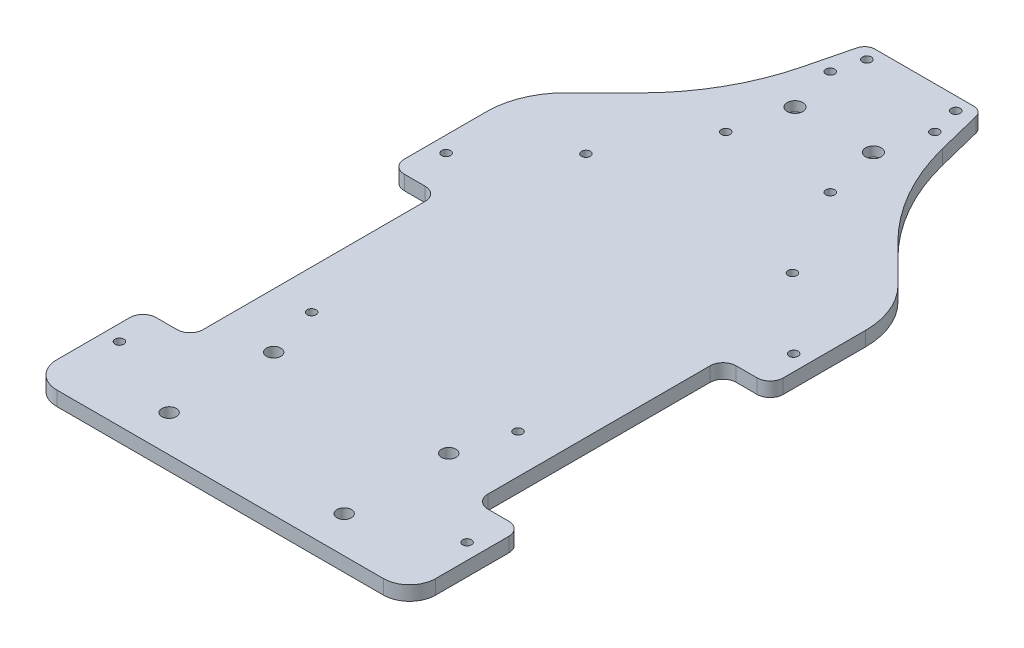
from build123d import *

# Parameters (mm, degrees)
DECK_BASE_DEPTH     = 5.5
BOLT_SLOT_REACH     = 7.5
SKETCH_3_R          = 1.7
FILLET_1_R          = 4
CUT_SIDE_REACH      = 7.5
SKETCH_11_W         = 18
SKETCH_11_H         = 95
CUT_TAIL_REACH      = 7.5
SKETCH_10_W         = 145
SKETCH_10_H         = 38.5
FILLET_2_R          = 10
FILLET_3_R          = 5
LIDAR_SLOT_REACH    = 7.5
SKETCH_4_R          = 1.7
VESC_SLOT_REACH     = 7.5
SKETCH_6_R          = 2.75
NANO_SLOT_REACH     = 7.5
SKETCH_7_R          = 1.7
CUT_EXTRUDE_3_REACH = 7.5
SKETCH_12_R         = 1.75
SKETCH_13_R         = 3
CUT_EXTRUDE_4_DEPTH = 3.7


with BuildPart() as part:
    # 스케치1 → Deck base (new body)
    with BuildSketch(Plane(origin=(0, 0, 0), x_dir=(1, 0, 0), z_dir=(0, 1, 0))):
        with BuildLine():
            Line((-72.5, 0), (-72.5, -180))
            ThreePointArc((-72.5, -180), (-69.571067812, -187.071067812), (-62.5, -190))
            Line((-62.5, -190), (-49.196112248, -190))
            ThreePointArc((-49.196112248, -190), (-47.589899161, -190.265015363), (-46.15395453, -191.031968194))
            Line((-46.15395453, -191.031968194), (-18.84604547, -211.968031806))
            ThreePointArc((-18.84604547, -211.968031806), (-17.410100839, -212.734984637), (-15.803887752, -213))
            Line((-15.803887752, -213), (15.803887752, -213))
            ThreePointArc((15.803887752, -213), (17.410100839, -212.734984637), (18.84604547, -211.968031806))
            Line((18.84604547, -211.968031806), (46.15395453, -191.031968194))
            ThreePointArc((46.15395453, -191.031968194), (47.589899161, -190.265015363), (49.196112248, -190))
            Line((49.196112248, -190), (62.5, -190))
            ThreePointArc((62.5, -190), (69.571067812, -187.071067812), (72.5, -180))
            Line((72.5, -180), (72.5, 0))
            ThreePointArc((72.5, 0), (70.204904333, 11.508182998), (63.670781605, 21.255540601))
            Line((63.670781605, 21.255540601), (49.478231298, 35.391496426))
            ThreePointArc((49.478231298, 35.391496426), (35.536990456, 53.662264501), (27, 75))
            Line((27, 75), (22, 95))
            Line((22, 95), (-22, 95))
            Line((-22, 95), (-27, 75))
            ThreePointArc((-27, 75), (-35.536990456, 53.662264501), (-49.478231298, 35.391496426))
            Line((-49.478231298, 35.391496426), (-63.670781605, 21.255540601))
            ThreePointArc((-63.670781605, 21.255540601), (-70.204904333, 11.508182998), (-72.5, 0))
        make_face()
    extrude(amount=DECK_BASE_DEPTH)

    # 스케치3 → Bolt slot (cut, up to next)
    with BuildSketch(Plane(origin=(0, 5.5, 0), x_dir=(1, 0, 0), z_dir=(0, 1, 0)), mode=Mode.PRIVATE) as bolt_slot_sk1:
        with Locations((17, 90)):
            Circle(SKETCH_3_R)
    bolt_slot_tool1 = extrude(bolt_slot_sk1.sketch, amount=-BOLT_SLOT_REACH, mode=Mode.PRIVATE) & part.part
    add(bolt_slot_tool1.solids().sort_by_distance((17, 5.5, -90))[0], mode=Mode.SUBTRACT)
    # 스케치3 → Bolt slot (cut, up to next)
    with BuildSketch(Plane(origin=(0, 5.5, 0), x_dir=(1, 0, 0), z_dir=(0, 1, 0)), mode=Mode.PRIVATE) as bolt_slot_sk2:
        with Locations((66.5, -146.5)):
            Circle(SKETCH_3_R)
    bolt_slot_tool2 = extrude(bolt_slot_sk2.sketch, amount=-BOLT_SLOT_REACH, mode=Mode.PRIVATE) & part.part
    add(bolt_slot_tool2.solids().sort_by_distance((66.5, 5.5, 146.5))[0], mode=Mode.SUBTRACT)
    # 스케치3 → Bolt slot (cut, up to next)
    with BuildSketch(Plane(origin=(0, 5.5, 0), x_dir=(1, 0, 0), z_dir=(0, 1, 0)), mode=Mode.PRIVATE) as bolt_slot_sk3:
        with Locations((66.5, -116.5)):
            Circle(SKETCH_3_R)
    bolt_slot_tool3 = extrude(bolt_slot_sk3.sketch, amount=-BOLT_SLOT_REACH, mode=Mode.PRIVATE) & part.part
    add(bolt_slot_tool3.solids().sort_by_distance((66.5, 5.5, 116.5))[0], mode=Mode.SUBTRACT)
    # 스케치3 → Bolt slot (cut, up to next)
    with BuildSketch(Plane(origin=(0, 5.5, 0), x_dir=(1, 0, 0), z_dir=(0, 1, 0)), mode=Mode.PRIVATE) as bolt_slot_sk4:
        with Locations((66.5, -51.5)):
            Circle(SKETCH_3_R)
    bolt_slot_tool4 = extrude(bolt_slot_sk4.sketch, amount=-BOLT_SLOT_REACH, mode=Mode.PRIVATE) & part.part
    add(bolt_slot_tool4.solids().sort_by_distance((66.5, 5.5, 51.5))[0], mode=Mode.SUBTRACT)
    # 스케치3 → Bolt slot (cut, up to next)
    with BuildSketch(Plane(origin=(0, 5.5, 0), x_dir=(1, 0, 0), z_dir=(0, 1, 0)), mode=Mode.PRIVATE) as bolt_slot_sk5:
        with Locations((66.5, -21.5)):
            Circle(SKETCH_3_R)
    bolt_slot_tool5 = extrude(bolt_slot_sk5.sketch, amount=-BOLT_SLOT_REACH, mode=Mode.PRIVATE) & part.part
    add(bolt_slot_tool5.solids().sort_by_distance((66.5, 5.5, 21.5))[0], mode=Mode.SUBTRACT)
    # 스케치3 → Bolt slot (cut, up to next)
    with BuildSketch(Plane(origin=(0, 5.5, 0), x_dir=(1, 0, 0), z_dir=(0, 1, 0)), mode=Mode.PRIVATE) as bolt_slot_sk6:
        with Locations((-66.5, -21.5)):
            Circle(SKETCH_3_R)
    bolt_slot_tool6 = extrude(bolt_slot_sk6.sketch, amount=-BOLT_SLOT_REACH, mode=Mode.PRIVATE) & part.part
    add(bolt_slot_tool6.solids().sort_by_distance((-66.5, 5.5, 21.5))[0], mode=Mode.SUBTRACT)
    # 스케치3 → Bolt slot (cut, up to next)
    with BuildSketch(Plane(origin=(0, 5.5, 0), x_dir=(1, 0, 0), z_dir=(0, 1, 0)), mode=Mode.PRIVATE) as bolt_slot_sk7:
        with Locations((-66.5, -51.5)):
            Circle(SKETCH_3_R)
    bolt_slot_tool7 = extrude(bolt_slot_sk7.sketch, amount=-BOLT_SLOT_REACH, mode=Mode.PRIVATE) & part.part
    add(bolt_slot_tool7.solids().sort_by_distance((-66.5, 5.5, 51.5))[0], mode=Mode.SUBTRACT)
    # 스케치3 → Bolt slot (cut, up to next)
    with BuildSketch(Plane(origin=(0, 5.5, 0), x_dir=(1, 0, 0), z_dir=(0, 1, 0)), mode=Mode.PRIVATE) as bolt_slot_sk8:
        with Locations((-66.5, -116.5)):
            Circle(SKETCH_3_R)
    bolt_slot_tool8 = extrude(bolt_slot_sk8.sketch, amount=-BOLT_SLOT_REACH, mode=Mode.PRIVATE) & part.part
    add(bolt_slot_tool8.solids().sort_by_distance((-66.5, 5.5, 116.5))[0], mode=Mode.SUBTRACT)
    # 스케치3 → Bolt slot (cut, up to next)
    with BuildSketch(Plane(origin=(0, 5.5, 0), x_dir=(1, 0, 0), z_dir=(0, 1, 0)), mode=Mode.PRIVATE) as bolt_slot_sk9:
        with Locations((-66.5, -146.5)):
            Circle(SKETCH_3_R)
    bolt_slot_tool9 = extrude(bolt_slot_sk9.sketch, amount=-BOLT_SLOT_REACH, mode=Mode.PRIVATE) & part.part
    add(bolt_slot_tool9.solids().sort_by_distance((-66.5, 5.5, 146.5))[0], mode=Mode.SUBTRACT)
    # 스케치3 → Bolt slot (cut, up to next)
    with BuildSketch(Plane(origin=(0, 5.5, 0), x_dir=(1, 0, 0), z_dir=(0, 1, 0)), mode=Mode.PRIVATE) as bolt_slot_sk10:
        with Locations((-17, 90)):
            Circle(SKETCH_3_R)
    bolt_slot_tool10 = extrude(bolt_slot_sk10.sketch, amount=-BOLT_SLOT_REACH, mode=Mode.PRIVATE) & part.part
    add(bolt_slot_tool10.solids().sort_by_distance((-17, 5.5, -90))[0], mode=Mode.SUBTRACT)

    # 필렛1
    fillet_1_edges = [part.edges().sort_by_distance(p)[0] for p in [
        (22, 2.75, -95),
        (-22, 2.75, -95),
    ]]
    fillet(fillet_1_edges, radius=FILLET_1_R)

    # 스케치11 → Cut side (cut, up to next)
    with BuildSketch(Plane(origin=(0, 5.5, 0), x_dir=(1, 0, 0), z_dir=(0, 1, 0)), mode=Mode.PRIVATE) as cut_side_sk1:
        with Locations((-63.5, -84)):
            Rectangle(SKETCH_11_W, SKETCH_11_H)
    cut_side_tool1 = extrude(cut_side_sk1.sketch, amount=-CUT_SIDE_REACH, mode=Mode.PRIVATE) & part.part
    add(cut_side_tool1.solids().sort_by_distance((-63.5, 5.5, 84))[0], mode=Mode.SUBTRACT)
    # 스케치11 → Cut side (cut, up to next)
    with BuildSketch(Plane(origin=(0, 5.5, 0), x_dir=(1, 0, 0), z_dir=(0, 1, 0)), mode=Mode.PRIVATE) as cut_side_sk2:
        with Locations((63.5, -84)):
            Rectangle(SKETCH_11_W, SKETCH_11_H)
    cut_side_tool2 = extrude(cut_side_sk2.sketch, amount=-CUT_SIDE_REACH, mode=Mode.PRIVATE) & part.part
    add(cut_side_tool2.solids().sort_by_distance((63.5, 5.5, 84))[0], mode=Mode.SUBTRACT)

    # 스케치10 → Cut tail (cut, up to next)
    with BuildSketch(Plane(origin=(0, 5.5, 0), x_dir=(1, 0, 0), z_dir=(0, 1, 0)), mode=Mode.PRIVATE) as cut_tail_sk1:
        with Locations((0, -193.75)):
            Rectangle(SKETCH_10_W, SKETCH_10_H)
    cut_tail_tool1 = extrude(cut_tail_sk1.sketch, amount=-CUT_TAIL_REACH, mode=Mode.PRIVATE) & part.part
    add(cut_tail_tool1.solids().sort_by_distance((0, 5.5, 193.75))[0], mode=Mode.SUBTRACT)

    # 필렛2
    fillet_2_edges = [part.edges().sort_by_distance(p)[0] for p in [
        (72.5, 2.75, 174.5),
        (-72.5, 2.75, 174.5),
    ]]
    fillet(fillet_2_edges, radius=FILLET_2_R)

    # 필렛3
    fillet_3_edges = [part.edges().sort_by_distance(p)[0] for p in [
        (-72.5, 2.75, 131.5),
        (-72.5, 2.75, 36.5),
        (-54.5, 2.75, 36.5),
        (-54.5, 2.75, 131.5),
        (72.5, 2.75, 36.5),
        (72.5, 2.75, 131.5),
        (54.5, 2.75, 131.5),
        (54.5, 2.75, 36.5),
    ]]
    fillet(fillet_3_edges, radius=FILLET_3_R)

    # 스케치4 → Lidar slot (cut, up to next)
    with BuildSketch(Plane(origin=(0, 5.5, 0), x_dir=(1, 0, 0), z_dir=(0, 1, 0)), mode=Mode.PRIVATE) as lidar_slot_sk1:
        with Locations((-20, 79)):
            Circle(SKETCH_4_R)
    lidar_slot_tool1 = extrude(lidar_slot_sk1.sketch, amount=-LIDAR_SLOT_REACH, mode=Mode.PRIVATE) & part.part
    add(lidar_slot_tool1.solids().sort_by_distance((-20, 5.5, -79))[0], mode=Mode.SUBTRACT)
    # 스케치4 → Lidar slot (cut, up to next)
    with BuildSketch(Plane(origin=(0, 5.5, 0), x_dir=(1, 0, 0), z_dir=(0, 1, 0)), mode=Mode.PRIVATE) as lidar_slot_sk2:
        with Locations((-20, 39)):
            Circle(SKETCH_4_R)
    lidar_slot_tool2 = extrude(lidar_slot_sk2.sketch, amount=-LIDAR_SLOT_REACH, mode=Mode.PRIVATE) & part.part
    add(lidar_slot_tool2.solids().sort_by_distance((-20, 5.5, -39))[0], mode=Mode.SUBTRACT)
    # 스케치4 → Lidar slot (cut, up to next)
    with BuildSketch(Plane(origin=(0, 5.5, 0), x_dir=(1, 0, 0), z_dir=(0, 1, 0)), mode=Mode.PRIVATE) as lidar_slot_sk3:
        with Locations((20, 39)):
            Circle(SKETCH_4_R)
    lidar_slot_tool3 = extrude(lidar_slot_sk3.sketch, amount=-LIDAR_SLOT_REACH, mode=Mode.PRIVATE) & part.part
    add(lidar_slot_tool3.solids().sort_by_distance((20, 5.5, -39))[0], mode=Mode.SUBTRACT)
    # 스케치4 → Lidar slot (cut, up to next)
    with BuildSketch(Plane(origin=(0, 5.5, 0), x_dir=(1, 0, 0), z_dir=(0, 1, 0)), mode=Mode.PRIVATE) as lidar_slot_sk4:
        with Locations((20, 79)):
            Circle(SKETCH_4_R)
    lidar_slot_tool4 = extrude(lidar_slot_sk4.sketch, amount=-LIDAR_SLOT_REACH, mode=Mode.PRIVATE) & part.part
    add(lidar_slot_tool4.solids().sort_by_distance((20, 5.5, -79))[0], mode=Mode.SUBTRACT)

    # 스케치6 → Vesc slot (cut, up to next)
    with BuildSketch(Plane(origin=(0, 5.5, 0), x_dir=(1, 0, 0), z_dir=(0, 1, 0)), mode=Mode.PRIVATE) as vesc_slot_sk1:
        with Locations((33.5, -120.5)):
            Circle(SKETCH_6_R)
    vesc_slot_tool1 = extrude(vesc_slot_sk1.sketch, amount=-VESC_SLOT_REACH, mode=Mode.PRIVATE) & part.part
    add(vesc_slot_tool1.solids().sort_by_distance((33.5, 5.5, 120.5))[0], mode=Mode.SUBTRACT)
    # 스케치6 → Vesc slot (cut, up to next)
    with BuildSketch(Plane(origin=(0, 5.5, 0), x_dir=(1, 0, 0), z_dir=(0, 1, 0)), mode=Mode.PRIVATE) as vesc_slot_sk2:
        with Locations((33.5, -160.5)):
            Circle(SKETCH_6_R)
    vesc_slot_tool2 = extrude(vesc_slot_sk2.sketch, amount=-VESC_SLOT_REACH, mode=Mode.PRIVATE) & part.part
    add(vesc_slot_tool2.solids().sort_by_distance((33.5, 5.5, 160.5))[0], mode=Mode.SUBTRACT)
    # 스케치6 → Vesc slot (cut, up to next)
    with BuildSketch(Plane(origin=(0, 5.5, 0), x_dir=(1, 0, 0), z_dir=(0, 1, 0)), mode=Mode.PRIVATE) as vesc_slot_sk3:
        with Locations((-33.5, -160.5)):
            Circle(SKETCH_6_R)
    vesc_slot_tool3 = extrude(vesc_slot_sk3.sketch, amount=-VESC_SLOT_REACH, mode=Mode.PRIVATE) & part.part
    add(vesc_slot_tool3.solids().sort_by_distance((-33.5, 5.5, 160.5))[0], mode=Mode.SUBTRACT)
    # 스케치6 → Vesc slot (cut, up to next)
    with BuildSketch(Plane(origin=(0, 5.5, 0), x_dir=(1, 0, 0), z_dir=(0, 1, 0)), mode=Mode.PRIVATE) as vesc_slot_sk4:
        with Locations((-33.5, -120.5)):
            Circle(SKETCH_6_R)
    vesc_slot_tool4 = extrude(vesc_slot_sk4.sketch, amount=-VESC_SLOT_REACH, mode=Mode.PRIVATE) & part.part
    add(vesc_slot_tool4.solids().sort_by_distance((-33.5, 5.5, 120.5))[0], mode=Mode.SUBTRACT)

    # 스케치7 → Nano slot (cut, up to next)
    with BuildSketch(Plane(origin=(0, 5.5, 0), x_dir=(1, 0, 0), z_dir=(0, 1, 0)), mode=Mode.PRIVATE) as nano_slot_sk1:
        with Locations((39.5, 5)):
            Circle(SKETCH_7_R)
    nano_slot_tool1 = extrude(nano_slot_sk1.sketch, amount=-NANO_SLOT_REACH, mode=Mode.PRIVATE) & part.part
    add(nano_slot_tool1.solids().sort_by_distance((39.5, 5.5, -5))[0], mode=Mode.SUBTRACT)
    # 스케치7 → Nano slot (cut, up to next)
    with BuildSketch(Plane(origin=(0, 5.5, 0), x_dir=(1, 0, 0), z_dir=(0, 1, 0)), mode=Mode.PRIVATE) as nano_slot_sk2:
        with Locations((39.5, -100)):
            Circle(SKETCH_7_R)
    nano_slot_tool2 = extrude(nano_slot_sk2.sketch, amount=-NANO_SLOT_REACH, mode=Mode.PRIVATE) & part.part
    add(nano_slot_tool2.solids().sort_by_distance((39.5, 5.5, 100))[0], mode=Mode.SUBTRACT)
    # 스케치7 → Nano slot (cut, up to next)
    with BuildSketch(Plane(origin=(0, 5.5, 0), x_dir=(1, 0, 0), z_dir=(0, 1, 0)), mode=Mode.PRIVATE) as nano_slot_sk3:
        with Locations((-39.5, -100)):
            Circle(SKETCH_7_R)
    nano_slot_tool3 = extrude(nano_slot_sk3.sketch, amount=-NANO_SLOT_REACH, mode=Mode.PRIVATE) & part.part
    add(nano_slot_tool3.solids().sort_by_distance((-39.5, 5.5, 100))[0], mode=Mode.SUBTRACT)
    # 스케치7 → Nano slot (cut, up to next)
    with BuildSketch(Plane(origin=(0, 5.5, 0), x_dir=(1, 0, 0), z_dir=(0, 1, 0)), mode=Mode.PRIVATE) as nano_slot_sk4:
        with Locations((-39.5, 5)):
            Circle(SKETCH_7_R)
    nano_slot_tool4 = extrude(nano_slot_sk4.sketch, amount=-NANO_SLOT_REACH, mode=Mode.PRIVATE) & part.part
    add(nano_slot_tool4.solids().sort_by_distance((-39.5, 5.5, -5))[0], mode=Mode.SUBTRACT)

    # 스케치12 → 컷-돌출3 (cut, up to next)
    with BuildSketch(Plane(origin=(0, 5.5, 0), x_dir=(1, 0, 0), z_dir=(0, 1, 0)), mode=Mode.PRIVATE) as cut_extrude_3_sk1:
        with Locations((-15, 60.5)):
            Circle(SKETCH_12_R)
    cut_extrude_3_tool1 = extrude(cut_extrude_3_sk1.sketch, amount=-CUT_EXTRUDE_3_REACH, mode=Mode.PRIVATE) & part.part
    add(cut_extrude_3_tool1.solids().sort_by_distance((-15, 5.5, -60.5))[0], mode=Mode.SUBTRACT)
    # 스케치12 → 컷-돌출3 (cut, up to next)
    with BuildSketch(Plane(origin=(0, 5.5, 0), x_dir=(1, 0, 0), z_dir=(0, 1, 0)), mode=Mode.PRIVATE) as cut_extrude_3_sk2:
        with Locations((15, 60.5)):
            Circle(SKETCH_12_R)
    cut_extrude_3_tool2 = extrude(cut_extrude_3_sk2.sketch, amount=-CUT_EXTRUDE_3_REACH, mode=Mode.PRIVATE) & part.part
    add(cut_extrude_3_tool2.solids().sort_by_distance((15, 5.5, -60.5))[0], mode=Mode.SUBTRACT)

    # 스케치13 → 컷-돌출4 (cut)
    with BuildSketch(Plane(origin=(0, 5.5, 0), x_dir=(1, 0, 0), z_dir=(0, 1, 0))):
        with Locations((-15, 60.5)):
            Circle(SKETCH_13_R)
        with Locations((15, 60.5)):
            Circle(SKETCH_13_R)
    extrude(amount=-CUT_EXTRUDE_4_DEPTH, mode=Mode.SUBTRACT)


solid = part.part
